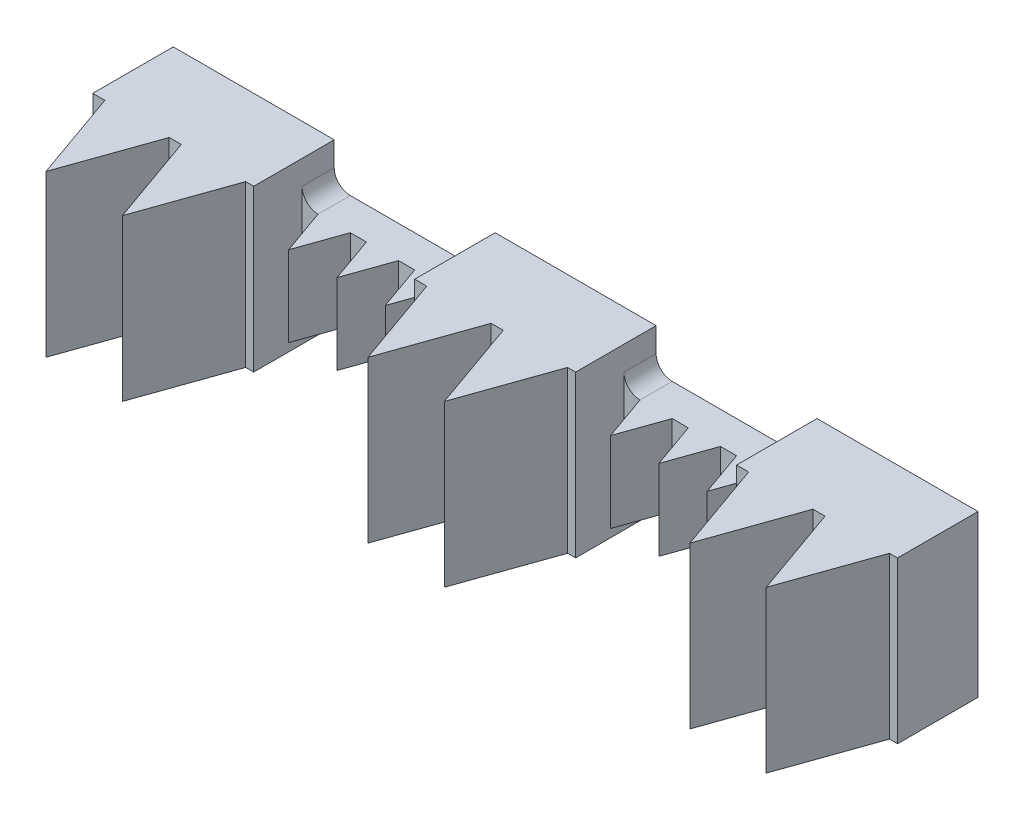
from build123d import *

# Parameters (mm, degrees)
SKETCH1_W            = 20
SKETCH1_H            = 20
BOSS_EXTRUDE1_DEPTH  = 10
SKETCH2_W            = 4
SKETCH2_H            = 10
BOSS_EXTRUDE2_DEPTH  = 20
SKETCH3_W            = 10
SKETCH3_H            = 20
BOSS_EXTRUDE3_DEPTH  = 20
SKETCH4_W            = 4
SKETCH4_H            = 10
BOSS_EXTRUDE4_DEPTH  = 20
SKETCH5_W            = 10
SKETCH5_H            = 20
BOSS_EXTRUDE5_DEPTH  = 20
BOSS_EXTRUDE6_DEPTH  = 20
BOSS_EXTRUDE7_DEPTH  = 20
BOSS_EXTRUDE8_DEPTH  = 10
SKETCH9_R            = 1.45
CUT_EXTRUDE1_DEPTH   = 1.5
SKETCH10_W           = 8
SKETCH10_H           = 18
CUT_EXTRUDE2_DEPTH   = 17
SKETCH13_W           = 8
SKETCH13_H           = 18
CUT_EXTRUDE4_DEPTH   = 19
SKETCH14_W           = 10
SKETCH14_H           = 20
BOSS_EXTRUDE9_DEPTH  = 1
SKETCH15_W           = 8
SKETCH15_H           = 18
CUT_EXTRUDE5_DEPTH   = 19
SKETCH16_W           = 10
SKETCH16_H           = 20
BOSS_EXTRUDE10_DEPTH = 1
SKETCH12_W           = 2
SKETCH12_H           = 8
CUT_EXTRUDE3_DEPTH   = 80
CUT_EXTRUDE7_DEPTH   = 19
SKETCH19_W           = 5.878679656
SKETCH19_H           = 18
CUT_EXTRUDE8_DEPTH   = 5
BOSS_EXTRUDE12_DEPTH = 1
CUT_EXTRUDE10_DEPTH  = 9
SKETCH23_W           = 2.302943726
SKETCH23_H           = 8
CUT_EXTRUDE11_DEPTH  = 3
BOSS_EXTRUDE13_DEPTH = 1
FILLET3_R            = 2
FILLET4_R            = 2


with BuildPart() as part:
    # Sketch1 → Boss-Extrude1 (new body)
    with BuildSketch(Plane.XY):
        Rectangle(SKETCH1_W, SKETCH1_H)
    extrude(amount=BOSS_EXTRUDE1_DEPTH)

    # Sketch2 → Boss-Extrude2 (add)
    with BuildSketch(Plane(origin=(10, 0, 0), x_dir=(0, 0, -1), z_dir=(1, 0, 0))):
        with Locations((-2, 0)):
            Rectangle(SKETCH2_W, SKETCH2_H)
    extrude(amount=BOSS_EXTRUDE2_DEPTH)

    # Sketch3 → Boss-Extrude3 (add)
    with BuildSketch(Plane(origin=(30, 0, 0), x_dir=(0, 0, -1), z_dir=(1, 0, 0))):
        with Locations((-5, 0)):
            Rectangle(SKETCH3_W, SKETCH3_H)
    extrude(amount=BOSS_EXTRUDE3_DEPTH)

    # Sketch4 → Boss-Extrude4 (add)
    with BuildSketch(Plane(origin=(50, 0, 0), x_dir=(0, 0, -1), z_dir=(1, 0, 0))):
        with Locations((-2, 0)):
            Rectangle(SKETCH4_W, SKETCH4_H)
    extrude(amount=BOSS_EXTRUDE4_DEPTH)

    # Sketch5 → Boss-Extrude5 (add)
    with BuildSketch(Plane(origin=(70, 0, 0), x_dir=(0, 0, -1), z_dir=(1, 0, 0))):
        with Locations((-5, 0)):
            Rectangle(SKETCH5_W, SKETCH5_H)
    extrude(amount=BOSS_EXTRUDE5_DEPTH)

    # Sketch6 → Boss-Extrude6 (add)
    with BuildSketch(Plane.XZ.offset(10)):
        Polygon((-8.5, 10), (-4.5, 21.313708499), (-0.5, 10), align=None)
        Polygon((9, 10), (1, 10), (5, 21.313708499), align=None)
    extrude(amount=-BOSS_EXTRUDE6_DEPTH)

    # Sketch7 → Boss-Extrude7 (add)
    with BuildSketch(Plane.XZ.offset(10)):
        Polygon((31.5, 10), (35.5, 21.313708499), (39.5, 10), align=None)
        Polygon((71.5, 10), (75.5, 21.313708499), (79.5, 10), align=None)
        Polygon((41, 10), (49, 10), (45, 21.313708499), align=None)
        Polygon((81, 10), (89, 10), (85, 21.313708499), align=None)
    extrude(amount=-BOSS_EXTRUDE7_DEPTH)

    # Sketch8 → Boss-Extrude8 (add)
    with BuildSketch(Plane.XZ.offset(5)):
        Polygon((12, 4), (14, 9.656854249), (16, 4), align=None)
        Polygon((52, 4), (54, 9.656854249), (56, 4), align=None)
        Polygon((18, 4), (22, 4), (20, 9.656854249), align=None)
        Polygon((58, 4), (62, 4), (60, 9.656854249), align=None)
        Polygon((24, 4), (28, 4), (26, 9.656854249), align=None)
        Polygon((64, 4), (68, 4), (66, 9.656854249), align=None)
    extrude(amount=-BOSS_EXTRUDE8_DEPTH)

    # Sketch9 → Cut-Extrude1 (cut)
    with BuildSketch(Plane.ZY.offset(10)):
        with Locations((7, 0)):
            Circle(SKETCH9_R)
    extrude(amount=-CUT_EXTRUDE1_DEPTH, mode=Mode.SUBTRACT)

    # Sketch10 → Cut-Extrude2 (cut)
    with BuildSketch(Plane.ZY.offset(8.5)):
        with Locations((5, 0)):
            Rectangle(SKETCH10_W, SKETCH10_H)
    extrude(amount=-CUT_EXTRUDE2_DEPTH, mode=Mode.SUBTRACT)

    # Sketch13 → Cut-Extrude4 (cut)
    with BuildSketch(Plane.ZY.offset(-30)):
        with Locations((5, 0)):
            Rectangle(SKETCH13_W, SKETCH13_H)
    extrude(amount=-CUT_EXTRUDE4_DEPTH, mode=Mode.SUBTRACT)

    # Sketch14 → Boss-Extrude9 (add)
    with BuildSketch(Plane.ZY.offset(-30)):
        with Locations((5, 0)):
            Rectangle(SKETCH14_W, SKETCH14_H)
    extrude(amount=-BOSS_EXTRUDE9_DEPTH)

    # Sketch15 → Cut-Extrude5 (cut)
    with BuildSketch(Plane.ZY.offset(-70)):
        with Locations((5, 0)):
            Rectangle(SKETCH15_W, SKETCH15_H)
    extrude(amount=-CUT_EXTRUDE5_DEPTH, mode=Mode.SUBTRACT)

    # Sketch16 → Boss-Extrude10 (add)
    with BuildSketch(Plane.ZY.offset(-70)):
        with Locations((5, 0)):
            Rectangle(SKETCH16_W, SKETCH16_H)
    extrude(amount=-BOSS_EXTRUDE10_DEPTH)

    # Sketch12 → Cut-Extrude3 (cut)
    with BuildSketch(Plane.ZY.offset(-8.5)):
        with Locations((2, 0)):
            Rectangle(SKETCH12_W, SKETCH12_H)
    extrude(amount=-CUT_EXTRUDE3_DEPTH, mode=Mode.SUBTRACT)

    # Sketch17 → Cut-Extrude7 (cut)
    with BuildSketch(Plane.XZ.offset(10)):
        Polygon((-7.439339828, 10), (-4.5, 18.313708499), (-1.560660172, 10), align=None)
        Polygon((32.560660172, 10), (35.5, 18.313708499), (38.439339828, 10), align=None)
        Polygon((72.560660172, 10), (75.5, 18.313708499), (78.439339828, 10), align=None)
        Polygon((7.939339828, 10), (2.060660172, 10), (5, 18.313708499), align=None)
        Polygon((47.939339828, 10), (42.060660172, 10), (45, 18.313708499), align=None)
        Polygon((87.939339828, 10), (82.060660172, 10), (85, 18.313708499), align=None)
    extrude(amount=-CUT_EXTRUDE7_DEPTH, mode=Mode.SUBTRACT)

    # Sketch19 → Cut-Extrude8 (cut)
    with BuildSketch(Plane.XY.offset(10)):
        with Locations((-4.5, 0)):
            Rectangle(SKETCH19_W, SKETCH19_H)
        with Locations((35.5, 0)):
            Rectangle(SKETCH19_W, SKETCH19_H)
        with Locations((75.5, 0)):
            Rectangle(SKETCH19_W, SKETCH19_H)
        with Locations((5, 0)):
            Rectangle(SKETCH19_W, SKETCH19_H)
        with Locations((45, 0)):
            Rectangle(SKETCH19_W, SKETCH19_H)
        with Locations((85, 0)):
            Rectangle(SKETCH19_W, SKETCH19_H)
    extrude(amount=-CUT_EXTRUDE8_DEPTH, mode=Mode.SUBTRACT)

    # Sketch21 → Boss-Extrude12 (add)
    with BuildSketch(Plane.XZ.offset(10)):
        Polygon((-8.5, 10), (-4.5, 21.313708499), (-0.5, 10), align=None)
        Polygon((31.5, 10), (35.5, 21.313708499), (39.5, 10), align=None)
        Polygon((71.5, 10), (75.5, 21.313708499), (79.5, 10), align=None)
        Polygon((9, 10), (1, 10), (5, 21.313708499), align=None)
        Polygon((49, 10), (41, 10), (45, 21.313708499), align=None)
        Polygon((81, 10), (89, 10), (85, 21.313708499), align=None)
    extrude(amount=-BOSS_EXTRUDE12_DEPTH)

    # Sketch22 → Cut-Extrude10 (cut)
    with BuildSketch(Plane.XZ.offset(5)):
        Polygon((12.848528137, 4), (14, 7.256854249), (15.151471863, 4), align=None)
        Polygon((52.848528137, 4), (54, 7.256854249), (55.151471863, 4), align=None)
        Polygon((21.151471863, 4), (18.848528137, 4), (20, 7.256854249), align=None)
        Polygon((61.151471863, 4), (58.848528137, 4), (60, 7.256854249), align=None)
        Polygon((27.151471863, 4), (24.848528137, 4), (26, 7.256854249), align=None)
        Polygon((67.151471863, 4), (64.848528137, 4), (66, 7.256854249), align=None)
    extrude(amount=-CUT_EXTRUDE10_DEPTH, mode=Mode.SUBTRACT)

    # Sketch23 → Cut-Extrude11 (cut)
    with BuildSketch(Plane.XY.offset(4)):
        with Locations((14, 0)):
            Rectangle(SKETCH23_W, SKETCH23_H)
        with Locations((54, 0)):
            Rectangle(SKETCH23_W, SKETCH23_H)
        with Locations((20, 0)):
            Rectangle(SKETCH23_W, SKETCH23_H)
        with Locations((60, 0)):
            Rectangle(SKETCH23_W, SKETCH23_H)
        with Locations((26, 0)):
            Rectangle(SKETCH23_W, SKETCH23_H)
        with Locations((66, 0)):
            Rectangle(SKETCH23_W, SKETCH23_H)
    extrude(amount=-CUT_EXTRUDE11_DEPTH, mode=Mode.SUBTRACT)

    # Sketch24 → Boss-Extrude13 (add)
    with BuildSketch(Plane.XZ.offset(5)):
        Polygon((12, 4), (14, 9.656854249), (16, 4), align=None)
        Polygon((52, 4), (54, 9.656854249), (56, 4), align=None)
        Polygon((22, 4), (18, 4), (20, 9.656854249), align=None)
        Polygon((62, 4), (58, 4), (60, 9.656854249), align=None)
        Polygon((28, 4), (24, 4), (26, 9.656854249), align=None)
        Polygon((68, 4), (64, 4), (66, 9.656854249), align=None)
    extrude(amount=-BOSS_EXTRUDE13_DEPTH)

    # Fillet3
    fillet3_edges = [part.edges().sort_by_distance(p)[0] for p in [
        (10, -5, 2),
    ]]
    fillet(fillet3_edges, radius=FILLET3_R)

    # Fillet4
    fillet4_edges = [part.edges().sort_by_distance(p)[0] for p in [
        (30, 5, 2),
        (50, 5, 2),
        (10, 5, 2),
        (70, 5, 2),
        (50, -5, 2),
        (70, -5, 2),
        (30, -5, 2),
    ]]
    fillet(fillet4_edges, radius=FILLET4_R)


solid = part.part
